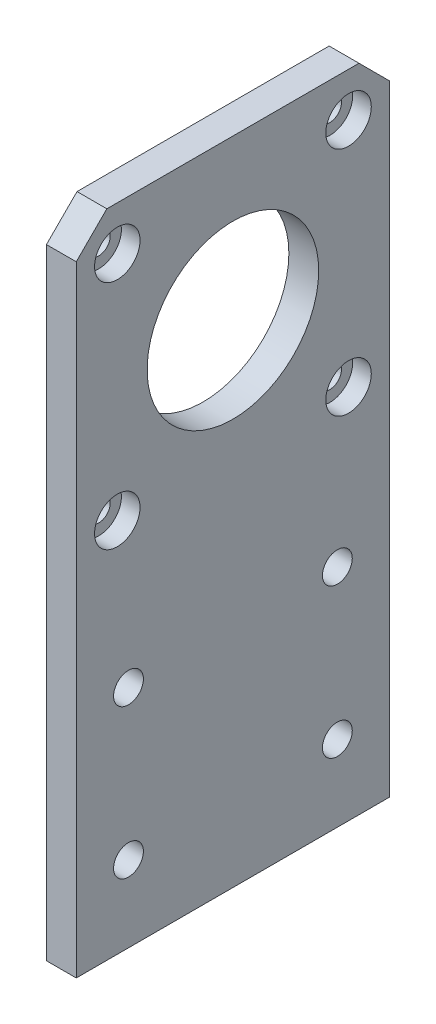
from build123d import *

# Parameters (mm, degrees)
CROQUIS1_W              = 42
CROQUIS1_H              = 87.25
SALIENTE_EXTRUIR1_DEPTH = 4
CROQUIS2_R              = 1.55
CROQUIS2_R_2            = 11.5
CORTAR_EXTRUIR1_DEPTH   = 5
CROQUIS3_R              = 2
CORTAR_EXTRUIR2_DEPTH   = 5
CHAFL_N1_SIZE           = 4.1
CROQUIS8_R              = 3.05
CORTAR_EXTRUIR3_DEPTH   = 2.5


with BuildPart() as part:
    # Croquis1 → Saliente-Extruir1 (new body)
    with BuildSketch(Plane(origin=(0, 0, 0), x_dir=(0, 0, -1), z_dir=(1, 0, 0))):
        Rectangle(CROQUIS1_W, CROQUIS1_H)
    extrude(amount=SALIENTE_EXTRUIR1_DEPTH)

    # Croquis2 → Cortar-Extruir1 (cut, through all)
    with BuildSketch(Plane(origin=(4, 0, 0), x_dir=(0, 0, -1), z_dir=(1, 0, 0))):
        with Locations((-15.5, 37.745)):
            Circle(CROQUIS2_R)
        with Locations((15.5, 37.745)):
            Circle(CROQUIS2_R)
        with Locations((15.5, 6.745)):
            Circle(CROQUIS2_R)
        with Locations((-15.5, 6.745)):
            Circle(CROQUIS2_R)
        with Locations((0, 22.245)):
            Circle(CROQUIS2_R_2)
    extrude(amount=-CORTAR_EXTRUIR1_DEPTH, mode=Mode.SUBTRACT)

    # Croquis3 → Cortar-Extruir2 (cut, through all)
    with BuildSketch(Plane(origin=(4, 0, 0), x_dir=(0, 0, -1), z_dir=(1, 0, 0))):
        with Locations((-14, -13.405)):
            Circle(CROQUIS3_R)
        with Locations((14, -13.405)):
            Circle(CROQUIS3_R)
        with Locations((-14, -33.405)):
            Circle(CROQUIS3_R)
        with Locations((14, -33.405)):
            Circle(CROQUIS3_R)
    extrude(amount=-CORTAR_EXTRUIR2_DEPTH, mode=Mode.SUBTRACT)

    # Chaflán1
    chafl_n1_edges = [part.edges().sort_by_distance(p)[0] for p in [
        (2, 43.625, 21),
        (2, 43.625, -21),
    ]]
    chamfer(chafl_n1_edges, length=CHAFL_N1_SIZE)

    # Croquis8 → Cortar-Extruir3 (cut)
    with BuildSketch(Plane(origin=(4, 0, 0), x_dir=(0, 0, -1), z_dir=(1, 0, 0))):
        with Locations((15.5, 37.745)):
            Circle(CROQUIS8_R)
        with Locations((-15.5, 37.745)):
            Circle(CROQUIS8_R)
        with Locations((-15.5, 6.745)):
            Circle(CROQUIS8_R)
        with Locations((15.5, 6.745)):
            Circle(CROQUIS8_R)
    extrude(amount=-CORTAR_EXTRUIR3_DEPTH, mode=Mode.SUBTRACT)


solid = part.part
